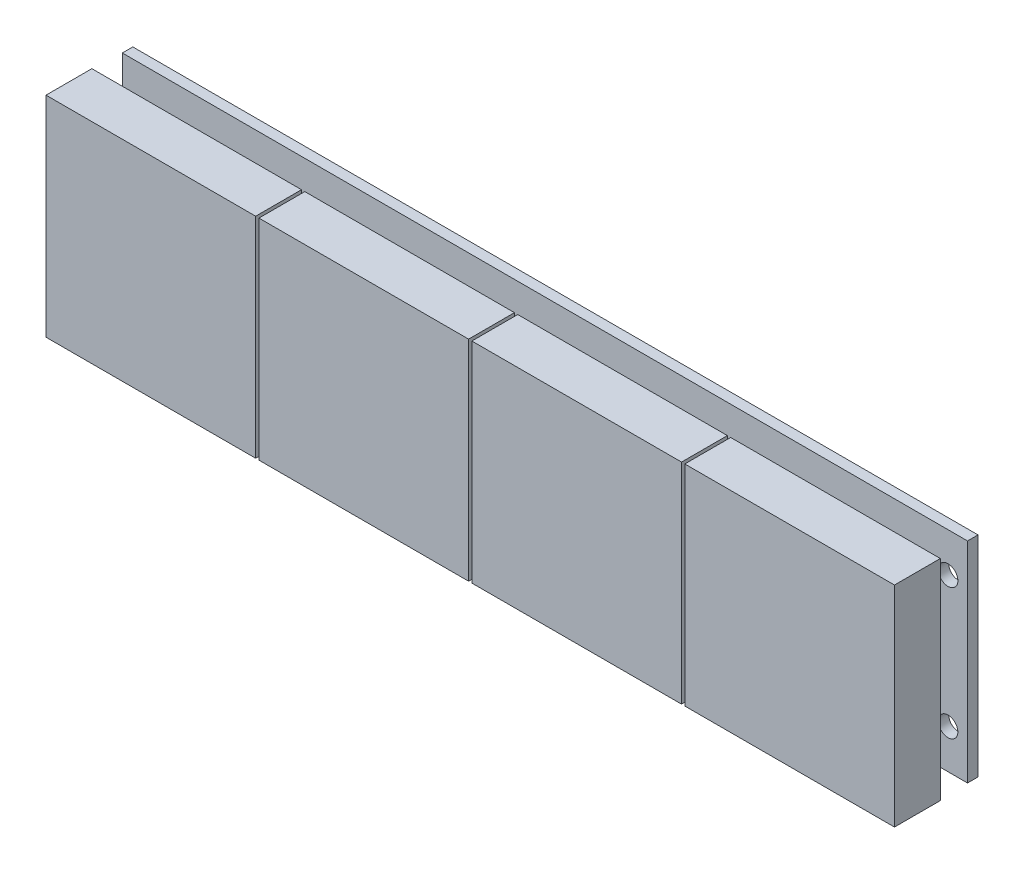
from build123d import *

# Parameters (mm, degrees)
SKETCH_1_W        = 129
SKETCH_1_H        = 32
SKETCH_1_R        = 1.5
EXTRUDE_1_DEPTH   = 1.6
EXTRUDE_START     = 4.4
SKETCH_2_W        = 32
SKETCH_2_H        = 32
EXTRUDE_2_DEPTH   = 7
EXTRUDE_2_2_DEPTH = 7
EXTRUDE_2_3_DEPTH = 7
EXTRUDE_2_4_DEPTH = 7


with BuildPart() as part:
    # Эскиз1 → Бобышка-Вытянуть1 (new body)
    with BuildSketch(Plane.XY):
        Rectangle(SKETCH_1_W, SKETCH_1_H)
        with Locations((-61.525, 10)):
            Circle(SKETCH_1_R, mode=Mode.SUBTRACT)
        with Locations((-61.525, -10)):
            Circle(SKETCH_1_R, mode=Mode.SUBTRACT)
        with Locations((-35.225, -10)):
            Circle(SKETCH_1_R, mode=Mode.SUBTRACT)
        with Locations((-35.225, 10)):
            Circle(SKETCH_1_R, mode=Mode.SUBTRACT)
        with Locations((-29.275, 10)):
            Circle(SKETCH_1_R, mode=Mode.SUBTRACT)
        with Locations((-29.275, -10)):
            Circle(SKETCH_1_R, mode=Mode.SUBTRACT)
        with Locations((-2.975, 10)):
            Circle(SKETCH_1_R, mode=Mode.SUBTRACT)
        with Locations((-2.975, -10)):
            Circle(SKETCH_1_R, mode=Mode.SUBTRACT)
        with Locations((2.975, 10)):
            Circle(SKETCH_1_R, mode=Mode.SUBTRACT)
        with Locations((2.975, -10)):
            Circle(SKETCH_1_R, mode=Mode.SUBTRACT)
        with Locations((29.275, 10)):
            Circle(SKETCH_1_R, mode=Mode.SUBTRACT)
        with Locations((29.275, -10)):
            Circle(SKETCH_1_R, mode=Mode.SUBTRACT)
        with Locations((35.225, 10)):
            Circle(SKETCH_1_R, mode=Mode.SUBTRACT)
        with Locations((35.225, -10)):
            Circle(SKETCH_1_R, mode=Mode.SUBTRACT)
        with Locations((61.525, 10)):
            Circle(SKETCH_1_R, mode=Mode.SUBTRACT)
        with Locations((61.525, -10)):
            Circle(SKETCH_1_R, mode=Mode.SUBTRACT)
    extrude(amount=EXTRUDE_1_DEPTH)


with BuildPart() as body_2:
    # Эскиз2 → Бобышка-Вытянуть2 (new body)
    with BuildSketch(Plane.XY.offset(1.6).offset(EXTRUDE_START)):
        with Locations((-48.75, 0)):
            Rectangle(SKETCH_2_W, SKETCH_2_H)
    extrude(amount=EXTRUDE_2_DEPTH)


with BuildPart() as body_3:
    # Эскиз2 → Extrude 2 2 (new body)
    with BuildSketch(Plane.XY.offset(1.6).offset(EXTRUDE_START)):
        with Locations((-16.25, 0)):
            Rectangle(SKETCH_2_W, SKETCH_2_H)
    extrude(amount=EXTRUDE_2_2_DEPTH)


with BuildPart() as body_4:
    # Эскиз2 → Extrude 2 3 (new body)
    with BuildSketch(Plane.XY.offset(1.6).offset(EXTRUDE_START)):
        with Locations((16.25, 0)):
            Rectangle(SKETCH_2_W, SKETCH_2_H)
    extrude(amount=EXTRUDE_2_3_DEPTH)


with BuildPart() as body_5:
    # Эскиз2 → Extrude 2 4 (new body)
    with BuildSketch(Plane.XY.offset(1.6).offset(EXTRUDE_START)):
        with Locations((48.75, 0)):
            Rectangle(SKETCH_2_W, SKETCH_2_H)
    extrude(amount=EXTRUDE_2_4_DEPTH)


solid = Compound([part.part, body_2.part, body_3.part, body_4.part, body_5.part])
